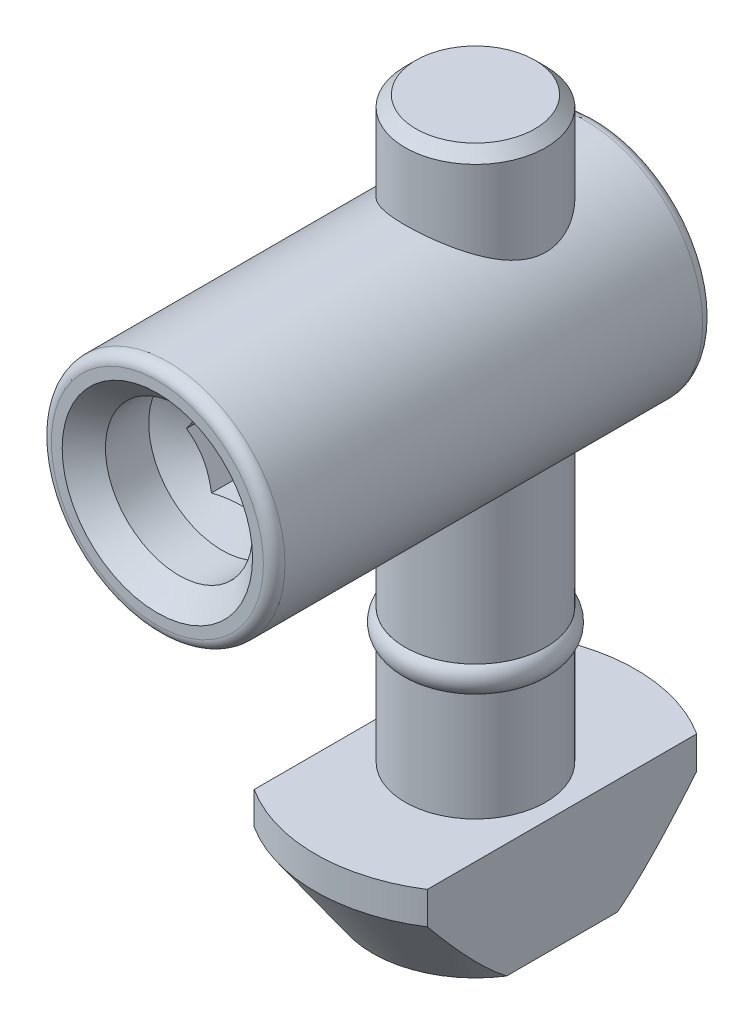
from build123d import *

# Parameters (mm, degrees)
SKETCH_6_OUTSIDE_W          = 24.448
SKETCH_6_OUTSIDE_H          = 24.448
SKETCH_6_OUTSIDE_W_2        = 8
SKETCH_6_OUTSIDE_H_2        = 14.8
CUT_EXTRUDE_1_DEPTH         = 5.3
CHAMFER_1_SIZE              = 0.5
SKETCH_12_R                 = 5.4
EXTRUDE_2_DEPTH             = 14.7
EXTRUDE_2_DEPTH_BACK        = 5.6
HOLE_WIZARD_M81_D           = 6.8
HOLE_WIZARD_M81_DEPTH       = 3
HOLE_WIZARD_M81_CSINK_D     = 8.8
HOLE_WIZARD_M81_CSINK_ANGLE = 90
HOLE_WIZARD_M81_TIP         = 2.042926105
FILLET_1_R                  = 0.5
CUT_EXTRUDE_2_DEPTH         = 6


with BuildPart() as part:
    # Эскиз3 → Повернуть1 (revolve)
    with BuildSketch(Plane.XY, mode=Mode.PRIVATE) as revolve_1_sk:
        Polygon((0, 0), (-3.25, 0), (-3.25, -20.5), (-2.75, -20.5), (-2.75, -21.7), (-3.25, -21.7), (-3.25, -26.7), (-7.4, -26.7), (-7.4, -28.2), (-4.75, -32), (0, -32), align=None)
    revolve(revolve_1_sk.sketch.rotate(Axis((0, 0, 0), (0, 1, 0)), 270), axis=Axis((0, 0, 0), (0, 1, 0)))  # turned: the seam where the file's is

    # Эскиз6 outside → Вырез-Вытянуть1 (cut)
    with BuildSketch(Plane.XZ.offset(32)):
        Rectangle(SKETCH_6_OUTSIDE_W, SKETCH_6_OUTSIDE_H)
        Rectangle(SKETCH_6_OUTSIDE_W_2, SKETCH_6_OUTSIDE_H_2, mode=Mode.SUBTRACT)
    extrude(amount=-CUT_EXTRUDE_1_DEPTH, mode=Mode.SUBTRACT)

    # Фаска1
    chamfer_1_edges = [part.edges().sort_by_distance(p)[0] for p in [
        (0, 0, 3.25),
    ]]
    chamfer(chamfer_1_edges, length=CHAMFER_1_SIZE)

    # Эскиз12 → Бобышка-Вытянуть2 (add, two sides)
    with BuildSketch(Plane.XY) as extrude_2_sk:
        with Locations((0, -9)):
            Circle(SKETCH_12_R)
    extrude(amount=EXTRUDE_2_DEPTH)
    extrude(extrude_2_sk.sketch, amount=-EXTRUDE_2_DEPTH_BACK)

    # Отверстие обработанное метчиком M81
    with Locations(Plane.XY.offset(14.7)):
        with Locations((0, -9)):
            CounterSinkHole(HOLE_WIZARD_M81_D / 2, HOLE_WIZARD_M81_CSINK_D / 2, depth=HOLE_WIZARD_M81_DEPTH, counter_sink_angle=HOLE_WIZARD_M81_CSINK_ANGLE)
            with Locations((0, 0, -(HOLE_WIZARD_M81_DEPTH + HOLE_WIZARD_M81_TIP / 2))):  # 118° drill point
                Cone(0, HOLE_WIZARD_M81_D / 2, HOLE_WIZARD_M81_TIP, mode=Mode.SUBTRACT)

    # Скругление1
    fillet_1_edges = [part.edges().sort_by_distance(p)[0] for p in [
        (-5.4, -9, -5.6),
        (-5.4, -9, 14.7),
    ]]
    fillet(fillet_1_edges, radius=FILLET_1_R)

    # Эскиз15 → Вырез-Вытянуть2 (cut)
    with BuildSketch(Plane.XY.offset(14.7)):
        Polygon((2.309401077, -9), (1.154700538, -7), (-1.154700538, -7), (-2.309401077, -9), (-1.154700538, -11), (1.154700538, -11), align=None)
    extrude(amount=-CUT_EXTRUDE_2_DEPTH, mode=Mode.SUBTRACT)


with BuildPart() as body_2:
    # Эскиз16 → Повернуть2 (revolve)
    with BuildSketch(Plane.XY, mode=Mode.PRIVATE) as revolve_2_sk:
        with BuildLine():
            Line((-2.75, -20.5), (-3.25, -20.5))
            ThreePointArc((-3.25, -20.5), (-3.531024968, -21.1), (-3.25, -21.7))
            Line((-3.25, -21.7), (-2.75, -21.7))
            Line((-2.75, -21.7), (-2.75, -20.5))
        make_face()
    revolve(revolve_2_sk.sketch.rotate(Axis((0, -20.5, 0), (0, -1, 0)), 90), axis=Axis((0, -20.5, 0), (0, -1, 0)))  # turned: the seam where the file's is


solid = Compound([part.part, body_2.part])
